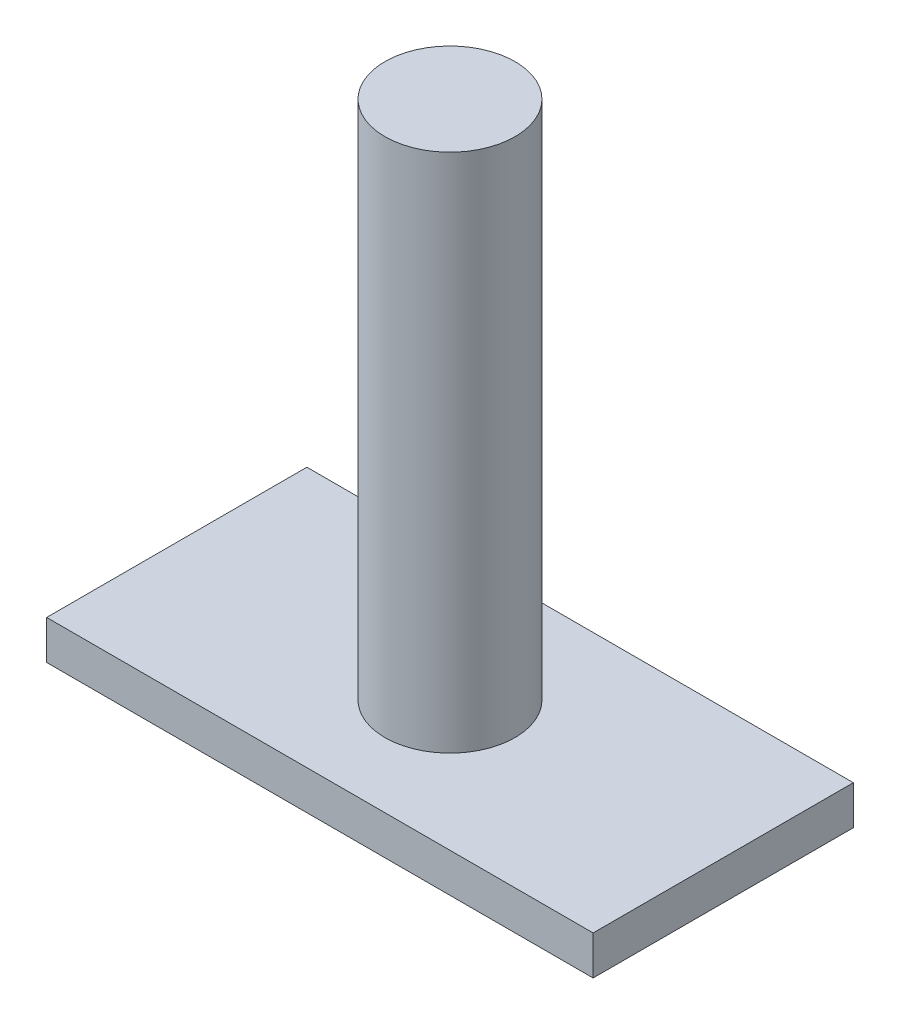
from build123d import *

# Parameters (mm, degrees)
SKETCH1_W           = 53.34
SKETCH1_H           = 25.4
BOSS_EXTRUDE1_DEPTH = 3.81
SKETCH2_R           = 6.35
BOSS_EXTRUDE2_DEPTH = 50.8


with BuildPart() as part:
    # Sketch1 → Boss-Extrude1 (new body)
    with BuildSketch(Plane(origin=(0, 0, 0), x_dir=(1, 0, 0), z_dir=(0, 1, 0))):
        with Locations((26.67, 12.7)):
            Rectangle(SKETCH1_W, SKETCH1_H)
    extrude(amount=BOSS_EXTRUDE1_DEPTH)

    # Sketch2 → Boss-Extrude2 (add)
    with BuildSketch(Plane(origin=(0, 3.81, 0), x_dir=(1, 0, 0), z_dir=(0, 1, 0))):
        with Locations((26.67, 12.7)):
            Circle(SKETCH2_R)
    extrude(amount=BOSS_EXTRUDE2_DEPTH)


solid = part.part
